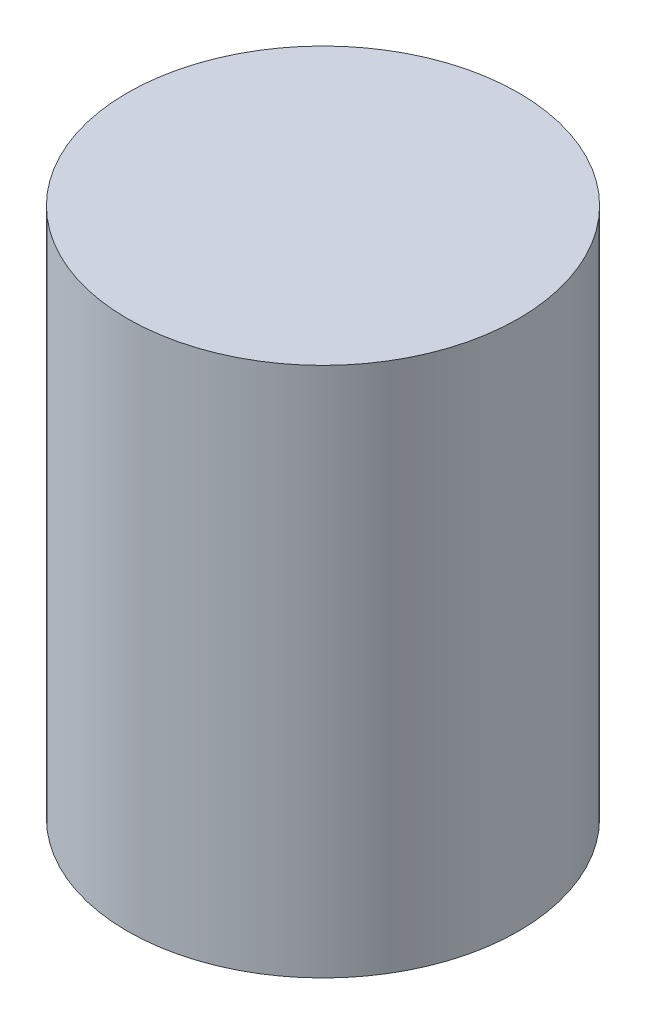
from build123d import *

# Parameters (mm, degrees)
SKETCH2_R           = 7.89
BOSS_EXTRUDE1_DEPTH = 21.4


with BuildPart() as part:
    # Sketch2 → Boss-Extrude1 (new body)
    with BuildSketch(Plane(origin=(0, 0, 0), x_dir=(1, 0, 0), z_dir=(0, 1, 0))):
        Circle(SKETCH2_R)
    extrude(amount=BOSS_EXTRUDE1_DEPTH)


solid = part.part
